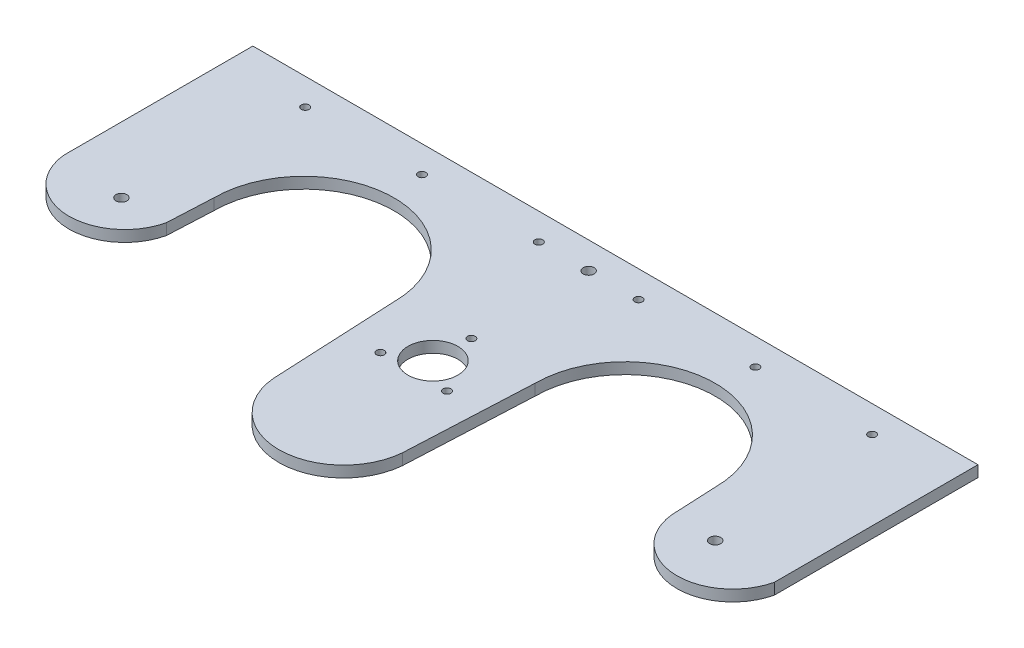
from build123d import *

# Parameters (mm, degrees)
ESQUISSE2_W                = 298
ESQUISSE2_H                = 145
BOSS_EXTRU_1_DEPTH         = 4.6
CREUX_STOCKAGE_VERRE_DEPTH = 46.6
ESQUISSE6_R                = 10.25
TROU_BILLE_DEPTH           = 5.6
ESQUISSE7_R                = 1.6
ENL_V_MAT_EXTRU_3_DEPTH    = 5.6
ENL_V_MAT_EXTRU_7_DEPTH    = 29
ESQUISSE17_R               = 1.6
ENL_V_MAT_EXTRU_14_DEPTH   = 4.6
BOSS_EXTRU_5_DEPTH         = 4.6
ENL_V_MAT_EXTRU_15_DEPTH   = 4.6
ENL_V_MAT_EXTRU_16_DEPTH   = 4.6
ESQUISSE12_R               = 2.25
ENL_V_MAT_EXTRU_17_DEPTH   = 10


with BuildPart() as part:
    # Esquisse2 → Boss.-Extru.1 (new body)
    with BuildSketch(Plane(origin=(0, 0, 0), x_dir=(1, 0, 0), z_dir=(0, 1, 0))):
        with Locations((149, 72.5)):
            Rectangle(ESQUISSE2_W, ESQUISSE2_H)
    extrude(amount=BOSS_EXTRU_1_DEPTH)

    # Esquisse3 → creux_stockage_verre (cut)
    with BuildSketch(Plane(origin=(0, 4.6, 0), x_dir=(1, 0, 0), z_dir=(0, 1, 0))):
        with BuildLine():
            Line((46, 83), (42, 0))
            Line((42, 0), (124, 0))
            Line((124, 0), (120, 83))
            ThreePointArc((120, 83), (83, 120), (46, 83))
        make_face()
        with BuildLine():
            Line((174, 0), (256, 0))
            Line((256, 0), (252, 83))
            ThreePointArc((252, 83), (215, 120), (178, 83))
            Line((178, 83), (174, 0))
        make_face()
    extrude(amount=-CREUX_STOCKAGE_VERRE_DEPTH, mode=Mode.SUBTRACT)

    # Esquisse6 → trou_bille (cut, through all)
    with BuildSketch(Plane(origin=(0, 4.6, 0), x_dir=(1, 0, 0), z_dir=(0, 1, 0))):
        with Locations((149, 70)):
            Circle(ESQUISSE6_R)
    extrude(amount=-TROU_BILLE_DEPTH, mode=Mode.SUBTRACT)

    # Esquisse7 → Enlèv. mat.-Extru.3 (cut, through all)
    with BuildSketch(Plane(origin=(0, 4.6, 0), x_dir=(1, 0, 0), z_dir=(0, 1, 0))):
        with Locations((32.5, 134)):
            Circle(ESQUISSE7_R)
        with Locations((80.5, 134)):
            Circle(ESQUISSE7_R)
        with Locations((128.5, 134)):
            Circle(ESQUISSE7_R)
        with Locations((217.5, 134)):
            Circle(ESQUISSE7_R)
        with Locations((169.5, 134)):
            Circle(ESQUISSE7_R)
        with Locations((265.5, 134)):
            Circle(ESQUISSE7_R)
    extrude(amount=-ENL_V_MAT_EXTRU_3_DEPTH, mode=Mode.SUBTRACT)

    # Esquisse9 → Enlèv. mat.-Extru.7 (cut)
    with BuildSketch(Plane(origin=(0, 4.6, 0), x_dir=(1, 0, 0), z_dir=(0, 1, 0))):
        with BuildLine():
            Line((123.101131567, 18.651519988), (120.058616356, -9.942070174))
            Line((120.058616356, -9.942070174), (178.789756957, -9.942070174))
            Line((178.789756957, -9.942070174), (174.898868433, 18.651519988))
            ThreePointArc((174.898868433, 18.651519988), (149, 12.489846239), (123.101131567, 18.651519988))
        make_face()
    extrude(amount=-ENL_V_MAT_EXTRU_7_DEPTH, mode=Mode.SUBTRACT)

    # Esquisse17 → Enlèv. mat.-Extru.14 (cut)
    with BuildSketch(Plane(origin=(0, 4.6, 0), x_dir=(1, 0, 0), z_dir=(0, 1, 0))):
        with Locations((149, 85.81)):
            Circle(ESQUISSE17_R)
        with Locations((135.308138366, 62.095)):
            Circle(ESQUISSE17_R)
        with Locations((162.691861634, 62.095)):
            Circle(ESQUISSE17_R)
    extrude(amount=-ENL_V_MAT_EXTRU_14_DEPTH, mode=Mode.SUBTRACT)

    # Esquisse15 → Boss.-Extru.5 (add)
    with BuildSketch(Plane(origin=(0, 4.6, 0), x_dir=(1, 0, 0), z_dir=(0, 1, 0))):
        with BuildLine():
            ThreePointArc((175.493975904, 31), (149, 6), (122.506024096, 31))
            ThreePointArc((122.506024096, 31), (149, 25.792591017), (175.493975904, 31))
        make_face()
    extrude(amount=-BOSS_EXTRU_5_DEPTH)

    # Esquisse18 → Enlèv. mat.-Extru.15 (cut)
    with BuildSketch(Plane(origin=(0, 4.6, 0), x_dir=(1, 0, 0), z_dir=(0, 1, 0))):
        with BuildLine():
            Line((175.493975904, 31), (178.847567105, -7.009778322))
            Line((178.847567105, -7.009778322), (115.973210985, -7.009778322))
            Line((115.973210985, -7.009778322), (122.506024096, 31))
            ThreePointArc((122.506024096, 31), (149, 6.694262171), (175.493975904, 31))
        make_face()
    extrude(amount=-ENL_V_MAT_EXTRU_15_DEPTH, mode=Mode.SUBTRACT)

    # Esquisse14 → Enlèv. mat.-Extru.16 (cut)
    with BuildSketch(Plane(origin=(0, 4.6, 0), x_dir=(1, 0, 0), z_dir=(0, 1, 0))):
        with BuildLine():
            Line((0, 71.707789669), (-22.158835411, -9.528975932))
            Line((-22.158835411, -9.528975932), (50.380974376, -9.528975932))
            Line((50.380974376, -9.528975932), (45.101419153, 64.354447432))
            ThreePointArc((45.101419153, 64.354447432), (19.112822484, 46.944980874), (0, 71.707789669))
        make_face()
        with BuildLine():
            Line((252.898580847, 64.354447432), (243.707235712, -12.373693019))
            Line((243.707235712, -12.373693019), (332.150206643, -12.373693019))
            Line((332.150206643, -12.373693019), (298, 71.707789669))
            ThreePointArc((298, 71.707789669), (279.381330699, 43.914112857), (252.898580847, 64.354447432))
        make_face()
    extrude(amount=-ENL_V_MAT_EXTRU_16_DEPTH, mode=Mode.SUBTRACT)

    # Esquisse12 → Enlèv. mat.-Extru.17 (cut)
    with BuildSketch(Plane(origin=(0, 4.6, 0), x_dir=(1, 0, 0), z_dir=(0, 1, 0))):
        with Locations((27, 64)):
            Circle(ESQUISSE12_R)
        with Locations((149, 134)):
            Circle(ESQUISSE12_R)
        with Locations((271, 64)):
            Circle(ESQUISSE12_R)
    extrude(amount=-ENL_V_MAT_EXTRU_17_DEPTH, mode=Mode.SUBTRACT)


solid = part.part
